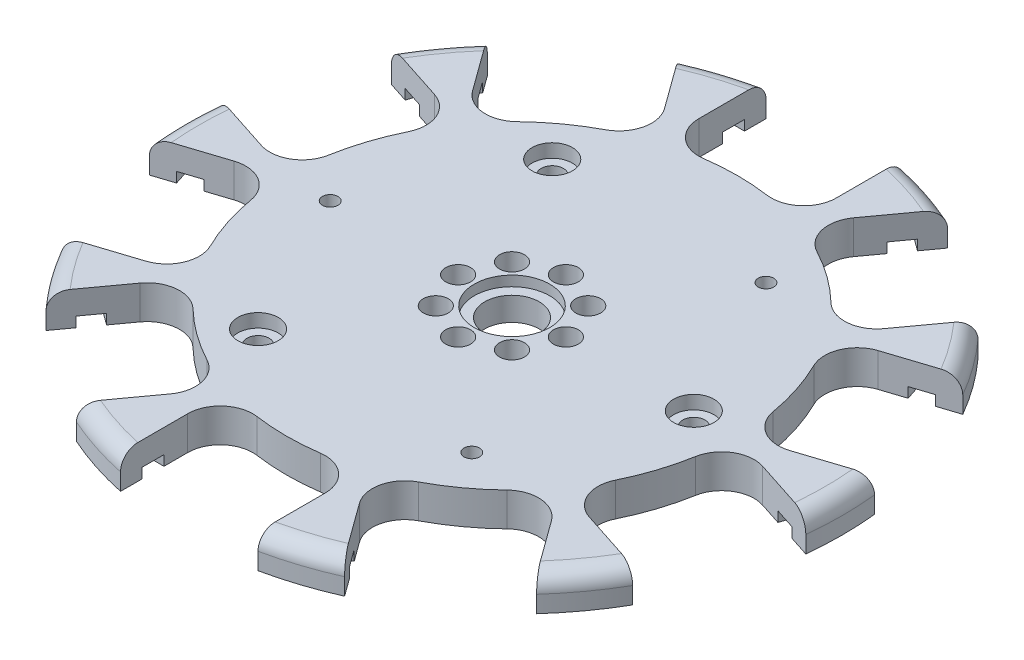
from build123d import *

# Parameters (mm, degrees)
SKETCH1_W                                        = 49
SKETCH1_H                                        = 5
CUT_EXTRUDE1_DEPTH                               = 6
CUT_EXTRUDE2_DEPTH                               = 6
CUT_EXTRUDE3_DEPTH                               = 6
CUT_EXTRUDE4_DEPTH                               = 6
CUT_EXTRUDE5_DEPTH                               = 6
CUT_EXTRUDE6_DEPTH                               = 6
CUT_EXTRUDE7_DEPTH                               = 6
CUT_EXTRUDE8_DEPTH                               = 6
CUT_EXTRUDE9_DEPTH                               = 6
CUT_EXTRUDE10_DEPTH                              = 6
SKETCH12_W                                       = 3.25
SKETCH12_H                                       = 1.5
CUT_EXTRUDE11_DEPTH                              = 2.772
SKETCH13_W                                       = 3.25
SKETCH13_H                                       = 1.5
CUT_EXTRUDE12_DEPTH                              = 2.772
SKETCH14_W                                       = 3.25
SKETCH14_H                                       = 1.5
CUT_EXTRUDE13_DEPTH                              = 2.772
SKETCH15_W                                       = 3.25
SKETCH15_H                                       = 1.5
CUT_EXTRUDE14_DEPTH                              = 2.772
SKETCH16_W                                       = 3.25
SKETCH16_H                                       = 1.5
CUT_EXTRUDE15_DEPTH                              = 2.772
SKETCH17_W                                       = 3.25
SKETCH17_H                                       = 1.5
CUT_EXTRUDE16_DEPTH                              = 2.772
SKETCH18_W                                       = 3.25
SKETCH18_H                                       = 1.5
CUT_EXTRUDE17_DEPTH                              = 2.772
SKETCH19_W                                       = 3.25
SKETCH19_H                                       = 1.5
CUT_EXTRUDE18_DEPTH                              = 2.772
SKETCH20_W                                       = 3.25
SKETCH20_H                                       = 1.5
CUT_EXTRUDE19_DEPTH                              = 2.772
SKETCH21_W                                       = 3.25
SKETCH21_H                                       = 1.5
CUT_EXTRUDE20_DEPTH                              = 2.772
SKETCH22_W                                       = 3.25
SKETCH22_H                                       = 1.5
CUT_EXTRUDE21_DEPTH                              = 2.772
SKETCH23_W                                       = 3.25
SKETCH23_H                                       = 1.5
CUT_EXTRUDE22_DEPTH                              = 2.772
SKETCH24_W                                       = 3.25
SKETCH24_H                                       = 1.5
CUT_EXTRUDE23_DEPTH                              = 2.772
SKETCH25_W                                       = 3.25
SKETCH25_H                                       = 1.5
CUT_EXTRUDE24_DEPTH                              = 2.772
SKETCH26_W                                       = 3.25
SKETCH26_H                                       = 1.5
CUT_EXTRUDE25_DEPTH                              = 2.772
SKETCH27_W                                       = 3.25
SKETCH27_H                                       = 1.5
CUT_EXTRUDE26_DEPTH                              = 2.772
SKETCH28_W                                       = 3.25
SKETCH28_H                                       = 1.5
CUT_EXTRUDE27_DEPTH                              = 2.772
SKETCH29_W                                       = 3.25
SKETCH29_H                                       = 1.5
CUT_EXTRUDE28_DEPTH                              = 2.772
SKETCH30_W                                       = 3.25
SKETCH30_H                                       = 1.5
CUT_EXTRUDE29_DEPTH                              = 2.772
SKETCH31_W                                       = 3.25
SKETCH31_H                                       = 1.5
CUT_EXTRUDE30_DEPTH                              = 2.772
F_2_3_2_3_DIAMETER_HOLE1_D                       = 2.3
F_2_3_2_3_DIAMETER_HOLE1_DEPTH                   = 5
F_3_7_3_7_DIAMETER_HOLE1_D                       = 3.7
F_3_7_3_7_DIAMETER_HOLE1_DEPTH                   = 5
CBORE_FOR_M3_HEX_HEAD_MACHINE_SCREW1_D           = 3.3
CBORE_FOR_M3_HEX_HEAD_MACHINE_SCREW1_DEPTH       = 5
CBORE_FOR_M3_HEX_HEAD_MACHINE_SCREW1_CBORE_D     = 6
CBORE_FOR_M3_HEX_HEAD_MACHINE_SCREW1_CBORE_DEPTH = 2
HOLE1_D                                          = 8.1
HOLE1_DEPTH                                      = 5
HOLE1_CBORE_D                                    = 11.2
HOLE1_CBORE_DEPTH                                = 1.5
FILLET1_R                                        = 2.5
FILLET2_R                                        = 4.827


with BuildPart() as part:
    # Sketch1 → Revolve1 (revolve)
    with BuildSketch(Plane(origin=(0, 0, 0), x_dir=(-1, 0, 0), z_dir=(0, 0, -1))):
        with Locations((-24.5, 2.5)):
            Rectangle(SKETCH1_W, SKETCH1_H)
    revolve(axis=Axis((0, 0, 0), (0, 1, 0)))

    # Sketch2 → Cut-Extrude1 (cut, through all)
    with BuildSketch(Plane.XZ):
        with BuildLine():
            Line((-10.205, 47.925546163), (-10.205, 31.907804296))
            ThreePointArc((-10.205, 31.907804296), (0, 33.5), (10.205, 31.907804296))
            Line((10.205, 31.907804296), (10.205, 47.925546163))
            ThreePointArc((10.205, 47.925546163), (0, 49), (-10.205, 47.925546163))
        make_face()
    extrude(amount=-CUT_EXTRUDE1_DEPTH, mode=Mode.SUBTRACT)

    # Sketch3 → Cut-Extrude2 (cut, through all)
    with BuildSketch(Plane.XZ):
        with BuildLine():
            Line((19.913910815, 44.77092981), (10.498918371, 31.812304428))
            ThreePointArc((10.498918371, 31.812304428), (19.690805952, 27.102069312), (27.010955226, 19.815607429))
            Line((27.010955226, 19.815607429), (36.42594767, 32.774232811))
            ThreePointArc((36.42594767, 32.774232811), (28.801477362, 39.641832724), (19.913910815, 44.77092981))
        make_face()
    extrude(amount=-CUT_EXTRUDE2_DEPTH, mode=Mode.SUBTRACT)

    # Sketch4 → Cut-Extrude3 (cut, through all)
    with BuildSketch(Plane.XZ):
        with BuildLine():
            Line((42.426384548, 24.515339978), (27.192606769, 19.565585529))
            ThreePointArc((27.192606769, 19.565585529), (31.860393296, 10.352069312), (33.499643624, 0.154522032))
            Line((33.499643624, 0.154522032), (48.733421403, 5.10427648))
            ThreePointArc((48.733421403, 5.10427648), (46.601769298, 15.141832724), (42.426384548, 24.515339978))
        make_face()
    extrude(amount=-CUT_EXTRUDE3_DEPTH, mode=Mode.SUBTRACT)

    # Sketch5 → Cut-Extrude4 (cut, through all)
    with BuildSketch(Plane.XZ):
        with BuildLine():
            Line((48.733421403, -5.10427648), (33.499643624, -0.154522032))
            ThreePointArc((33.499643624, -0.154522032), (31.860393296, -10.352069312), (27.192606769, -19.565585529))
            Line((27.192606769, -19.565585529), (42.426384548, -24.515339978))
            ThreePointArc((42.426384548, -24.515339978), (46.601769298, -15.141832724), (48.733421403, -5.10427648))
        make_face()
    extrude(amount=-CUT_EXTRUDE4_DEPTH, mode=Mode.SUBTRACT)

    # Sketch6 → Cut-Extrude5 (cut, through all)
    with BuildSketch(Plane.XZ):
        with BuildLine():
            Line((36.42594767, -32.774232811), (27.010955226, -19.815607429))
            ThreePointArc((27.010955226, -19.815607429), (19.690805952, -27.102069312), (10.498918371, -31.812304428))
            Line((10.498918371, -31.812304428), (19.913910815, -44.77092981))
            ThreePointArc((19.913910815, -44.77092981), (28.801477362, -39.641832724), (36.42594767, -32.774232811))
        make_face()
    extrude(amount=-CUT_EXTRUDE5_DEPTH, mode=Mode.SUBTRACT)

    # Sketch7 → Cut-Extrude6 (cut, through all)
    with BuildSketch(Plane.XZ):
        with BuildLine():
            Line((10.205, -47.925546163), (10.205, -31.907804296))
            ThreePointArc((10.205, -31.907804296), (0, -33.5), (-10.205, -31.907804296))
            Line((-10.205, -31.907804296), (-10.205, -47.925546163))
            ThreePointArc((-10.205, -47.925546163), (0, -49), (10.205, -47.925546163))
        make_face()
    extrude(amount=-CUT_EXTRUDE6_DEPTH, mode=Mode.SUBTRACT)

    # Sketch8 → Cut-Extrude7 (cut, through all)
    with BuildSketch(Plane.XZ):
        with BuildLine():
            Line((-19.913910815, -44.77092981), (-10.498918371, -31.812304428))
            ThreePointArc((-10.498918371, -31.812304428), (-19.690805952, -27.102069312), (-27.010955226, -19.815607429))
            Line((-27.010955226, -19.815607429), (-36.42594767, -32.774232811))
            ThreePointArc((-36.42594767, -32.774232811), (-28.801477362, -39.641832724), (-19.913910815, -44.77092981))
        make_face()
    extrude(amount=-CUT_EXTRUDE7_DEPTH, mode=Mode.SUBTRACT)

    # Sketch9 → Cut-Extrude8 (cut, through all)
    with BuildSketch(Plane.XZ):
        with BuildLine():
            Line((-42.426384548, -24.515339978), (-27.192606769, -19.565585529))
            ThreePointArc((-27.192606769, -19.565585529), (-31.860393296, -10.352069312), (-33.499643624, -0.154522032))
            Line((-33.499643624, -0.154522032), (-48.733421403, -5.10427648))
            ThreePointArc((-48.733421403, -5.10427648), (-46.601769298, -15.141832724), (-42.426384548, -24.515339978))
        make_face()
    extrude(amount=-CUT_EXTRUDE8_DEPTH, mode=Mode.SUBTRACT)

    # Sketch10 → Cut-Extrude9 (cut, through all)
    with BuildSketch(Plane.XZ):
        with BuildLine():
            Line((-48.733421403, 5.10427648), (-33.499643624, 0.154522032))
            ThreePointArc((-33.499643624, 0.154522032), (-31.860393296, 10.352069312), (-27.192606769, 19.565585529))
            Line((-27.192606769, 19.565585529), (-42.426384548, 24.515339978))
            ThreePointArc((-42.426384548, 24.515339978), (-46.601769298, 15.141832724), (-48.733421403, 5.10427648))
        make_face()
    extrude(amount=-CUT_EXTRUDE9_DEPTH, mode=Mode.SUBTRACT)

    # Sketch11 → Cut-Extrude10 (cut, through all)
    with BuildSketch(Plane.XZ):
        with BuildLine():
            Line((-36.42594767, 32.774232811), (-27.010955226, 19.815607429))
            ThreePointArc((-27.010955226, 19.815607429), (-19.690805952, 27.102069312), (-10.498918371, 31.812304428))
            Line((-10.498918371, 31.812304428), (-19.913910815, 44.77092981))
            ThreePointArc((-19.913910815, 44.77092981), (-28.801477362, 39.641832724), (-36.42594767, 32.774232811))
        make_face()
    extrude(amount=-CUT_EXTRUDE10_DEPTH, mode=Mode.SUBTRACT)

    # Sketch12 → Cut-Extrude11 (cut)
    with BuildSketch(Plane(origin=(8.256018428, 0, 5.9983485), x_dir=(-0.587785252, 0, 0.809016994), z_dir=(-0.809016994, 0, -0.587785252))):
        with Locations((43.105, 0.75)):
            Rectangle(SKETCH12_W, SKETCH12_H)
    extrude(amount=-CUT_EXTRUDE11_DEPTH, mode=Mode.SUBTRACT)

    # Sketch13 → Cut-Extrude12 (cut)
    with BuildSketch(Plane(origin=(-10.205, 0, 0), x_dir=(0, 0, -1), z_dir=(1, 0, 0))):
        with Locations((-43.105, 0.75)):
            Rectangle(SKETCH13_W, SKETCH13_H)
    extrude(amount=-CUT_EXTRUDE12_DEPTH, mode=Mode.SUBTRACT)

    # Sketch14 → Cut-Extrude13 (cut)
    with BuildSketch(Plane.ZY.offset(-10.205)):
        with Locations((43.105, 0.75)):
            Rectangle(SKETCH14_W, SKETCH14_H)
    extrude(amount=-CUT_EXTRUDE13_DEPTH, mode=Mode.SUBTRACT)

    # Sketch15 → Cut-Extrude14 (cut)
    with BuildSketch(Plane(origin=(-8.256018428, 0, 5.9983485), x_dir=(-0.587785252, 0, -0.809016994), z_dir=(0.809016994, 0, -0.587785252))):
        with Locations((-43.105, 0.75)):
            Rectangle(SKETCH15_W, SKETCH15_H)
    extrude(amount=-CUT_EXTRUDE14_DEPTH, mode=Mode.SUBTRACT)

    # Sketch16 → Cut-Extrude15 (cut)
    with BuildSketch(Plane(origin=(8.256018428, 0, -5.9983485), x_dir=(0.587785252, 0, 0.809016994), z_dir=(-0.809016994, 0, 0.587785252))):
        with Locations((43.105, 0.75)):
            Rectangle(SKETCH16_W, SKETCH16_H)
    extrude(amount=-CUT_EXTRUDE15_DEPTH, mode=Mode.SUBTRACT)

    # Sketch17 → Cut-Extrude16 (cut)
    with BuildSketch(Plane(origin=(-3.153518428, 0, 9.705531749), x_dir=(-0.951056516, 0, -0.309016994), z_dir=(0.309016994, 0, -0.951056516))):
        with Locations((-43.105, 0.75)):
            Rectangle(SKETCH17_W, SKETCH17_H)
    extrude(amount=-CUT_EXTRUDE16_DEPTH, mode=Mode.SUBTRACT)

    # Sketch18 → Cut-Extrude17 (cut)
    with BuildSketch(Plane(origin=(3.153518428, 0, -9.705531749), x_dir=(0.951056516, 0, 0.309016994), z_dir=(-0.309016994, 0, 0.951056516))):
        with Locations((43.105, 0.75)):
            Rectangle(SKETCH18_W, SKETCH18_H)
    extrude(amount=-CUT_EXTRUDE17_DEPTH, mode=Mode.SUBTRACT)

    # Sketch19 → Cut-Extrude18 (cut)
    with BuildSketch(Plane(origin=(3.153518428, 0, 9.705531749), x_dir=(-0.951056516, 0, 0.309016994), z_dir=(-0.309016994, 0, -0.951056516))):
        with Locations((-43.105, 0.75)):
            Rectangle(SKETCH19_W, SKETCH19_H)
    extrude(amount=-CUT_EXTRUDE18_DEPTH, mode=Mode.SUBTRACT)

    # Sketch20 → Cut-Extrude19 (cut)
    with BuildSketch(Plane(origin=(-3.153518428, 0, -9.705531749), x_dir=(0.951056516, 0, -0.309016994), z_dir=(0.309016994, 0, 0.951056516))):
        with Locations((43.105, 0.75)):
            Rectangle(SKETCH20_W, SKETCH20_H)
    extrude(amount=-CUT_EXTRUDE19_DEPTH, mode=Mode.SUBTRACT)

    # Sketch21 → Cut-Extrude20 (cut)
    with BuildSketch(Plane(origin=(8.256018428, 0, 5.9983485), x_dir=(-0.587785252, 0, 0.809016994), z_dir=(-0.809016994, 0, -0.587785252))):
        with Locations((-43.105, 0.75)):
            Rectangle(SKETCH21_W, SKETCH21_H)
    extrude(amount=-CUT_EXTRUDE20_DEPTH, mode=Mode.SUBTRACT)

    # Sketch22 → Cut-Extrude21 (cut)
    with BuildSketch(Plane(origin=(-8.256018428, 0, -5.9983485), x_dir=(0.587785252, 0, -0.809016994), z_dir=(0.809016994, 0, 0.587785252))):
        with Locations((43.105, 0.75)):
            Rectangle(SKETCH22_W, SKETCH22_H)
    extrude(amount=-CUT_EXTRUDE21_DEPTH, mode=Mode.SUBTRACT)

    # Sketch23 → Cut-Extrude22 (cut)
    with BuildSketch(Plane.ZY.offset(-10.205)):
        with Locations((-43.105, 0.75)):
            Rectangle(SKETCH23_W, SKETCH23_H)
    extrude(amount=-CUT_EXTRUDE22_DEPTH, mode=Mode.SUBTRACT)

    # Sketch24 → Cut-Extrude23 (cut)
    with BuildSketch(Plane(origin=(-10.205, 0, 0), x_dir=(0, 0, -1), z_dir=(1, 0, 0))):
        with Locations((43.105, 0.75)):
            Rectangle(SKETCH24_W, SKETCH24_H)
    extrude(amount=-CUT_EXTRUDE23_DEPTH, mode=Mode.SUBTRACT)

    # Sketch25 → Cut-Extrude24 (cut)
    with BuildSketch(Plane(origin=(8.256018428, 0, -5.9983485), x_dir=(0.587785252, 0, 0.809016994), z_dir=(-0.809016994, 0, 0.587785252))):
        with Locations((-43.105, 0.75)):
            Rectangle(SKETCH25_W, SKETCH25_H)
    extrude(amount=-CUT_EXTRUDE24_DEPTH, mode=Mode.SUBTRACT)

    # Sketch26 → Cut-Extrude25 (cut)
    with BuildSketch(Plane(origin=(-8.256018428, 0, 5.9983485), x_dir=(-0.587785252, 0, -0.809016994), z_dir=(0.809016994, 0, -0.587785252))):
        with Locations((43.105, 0.75)):
            Rectangle(SKETCH26_W, SKETCH26_H)
    extrude(amount=-CUT_EXTRUDE25_DEPTH, mode=Mode.SUBTRACT)

    # Sketch27 → Cut-Extrude26 (cut)
    with BuildSketch(Plane(origin=(3.153518428, 0, -9.705531749), x_dir=(0.951056516, 0, 0.309016994), z_dir=(-0.309016994, 0, 0.951056516))):
        with Locations((-43.105, 0.75)):
            Rectangle(SKETCH27_W, SKETCH27_H)
    extrude(amount=-CUT_EXTRUDE26_DEPTH, mode=Mode.SUBTRACT)

    # Sketch28 → Cut-Extrude27 (cut)
    with BuildSketch(Plane(origin=(-3.153518428, 0, 9.705531749), x_dir=(-0.951056516, 0, -0.309016994), z_dir=(0.309016994, 0, -0.951056516))):
        with Locations((43.105, 0.75)):
            Rectangle(SKETCH28_W, SKETCH28_H)
    extrude(amount=-CUT_EXTRUDE27_DEPTH, mode=Mode.SUBTRACT)

    # Sketch29 → Cut-Extrude28 (cut)
    with BuildSketch(Plane(origin=(-3.153518428, 0, -9.705531749), x_dir=(0.951056516, 0, -0.309016994), z_dir=(0.309016994, 0, 0.951056516))):
        with Locations((-43.105, 0.75)):
            Rectangle(SKETCH29_W, SKETCH29_H)
    extrude(amount=-CUT_EXTRUDE28_DEPTH, mode=Mode.SUBTRACT)

    # Sketch30 → Cut-Extrude29 (cut)
    with BuildSketch(Plane(origin=(3.153518428, 0, 9.705531749), x_dir=(-0.951056516, 0, 0.309016994), z_dir=(-0.309016994, 0, -0.951056516))):
        with Locations((43.105, 0.75)):
            Rectangle(SKETCH30_W, SKETCH30_H)
    extrude(amount=-CUT_EXTRUDE29_DEPTH, mode=Mode.SUBTRACT)

    # Sketch31 → Cut-Extrude30 (cut)
    with BuildSketch(Plane(origin=(-8.256018428, 0, -5.9983485), x_dir=(0.587785252, 0, -0.809016994), z_dir=(0.809016994, 0, 0.587785252))):
        with Locations((-43.105, 0.75)):
            Rectangle(SKETCH31_W, SKETCH31_H)
    extrude(amount=-CUT_EXTRUDE30_DEPTH, mode=Mode.SUBTRACT)

    # Ø2.3 (2.3) Diameter Hole1
    with Locations(Plane(origin=(0, 0, 0), x_dir=(-1, 0, 0), z_dir=(0, -1, 0))):
        with Locations((27, 0), (-15.870201812, 21.843458848), (-15.870201812, -21.843458848)):
            Hole(F_2_3_2_3_DIAMETER_HOLE1_D / 2, depth=F_2_3_2_3_DIAMETER_HOLE1_DEPTH)

    # Ø3.7 (3.7) Diameter Hole1
    with Locations(Plane(origin=(0, 0, 0), x_dir=(-1, 0, 0), z_dir=(0, -1, 0))):
        with Locations((8, 0), (5.656854249, -5.656854249), (0, -8), (-5.656854249, -5.656854249), (-8, 0), (-5.656854249, 5.656854249), (0, 8), (5.656854249, 5.656854249)):
            Hole(F_3_7_3_7_DIAMETER_HOLE1_D / 2, depth=F_3_7_3_7_DIAMETER_HOLE1_DEPTH)

    # CBORE for M3 Hex Head Machine Screw1
    with Locations(Plane(origin=(0, 5, 0), x_dir=(1, 0, 0), z_dir=(0, 1, 0))):
        with Locations((-15.870201812, 21.843458848), (-15.870201812, -21.843458848), (27, 0)):
            CounterBoreHole(CBORE_FOR_M3_HEX_HEAD_MACHINE_SCREW1_D / 2, CBORE_FOR_M3_HEX_HEAD_MACHINE_SCREW1_CBORE_D / 2, CBORE_FOR_M3_HEX_HEAD_MACHINE_SCREW1_CBORE_DEPTH, depth=CBORE_FOR_M3_HEX_HEAD_MACHINE_SCREW1_DEPTH)

    # Hole1
    with Locations(Plane(origin=(0, 5, 0), x_dir=(1, 0, 0), z_dir=(0, 1, 0))):
        with Locations((0, 0)):
            CounterBoreHole(HOLE1_D / 2, HOLE1_CBORE_D / 2, HOLE1_CBORE_DEPTH, depth=HOLE1_DEPTH)

    # Fillet1
    fillet1_edges = [part.edges().sort_by_distance(p)[0] for p in [
        (-39.641832724, 5, -28.801477362),
        (-49, 5, 0),
        (-39.641832724, 5, 28.801477362),
        (-15.141832724, 5, 46.601769298),
        (39.641832724, 5, 28.801477362),
        (15.141832724, 5, 46.601769298),
        (49, 5, 0),
        (39.641832724, 5, -28.801477362),
        (15.141832724, 5, -46.601769298),
        (-15.141832724, 5, -46.601769298),
    ]]
    fillet(fillet1_edges, radius=FILLET1_R)

    # Fillet2
    fillet2_edges = [part.edges().sort_by_distance(p)[0] for p in [
        (-27.010955226, 2.5, -19.815607429),
        (-10.498918371, 2.5, -31.812304428),
        (-33.499643624, 2.5, -0.154522032),
        (-27.192606769, 2.5, -19.565585529),
        (10.205, 2.5, 31.907804296),
        (-10.205, 2.5, 31.907804296),
        (-27.192606769, 2.5, 19.565585529),
        (-33.499643624, 2.5, 0.154522032),
        (-10.498918371, 2.5, 31.812304428),
        (-27.010955226, 2.5, 19.815607429),
        (27.010955226, 2.5, 19.815607429),
        (10.498918371, 2.5, 31.812304428),
        (33.499643624, 2.5, 0.154522032),
        (27.192606769, 2.5, 19.565585529),
        (27.192606769, 2.5, -19.565585529),
        (33.499643624, 2.5, -0.154522032),
        (10.498918371, 2.5, -31.812304428),
        (27.010955226, 2.5, -19.815607429),
        (-10.205, 2.5, -31.907804296),
        (10.205, 2.5, -31.907804296),
    ]]
    fillet(fillet2_edges, radius=FILLET2_R)


solid = part.part
